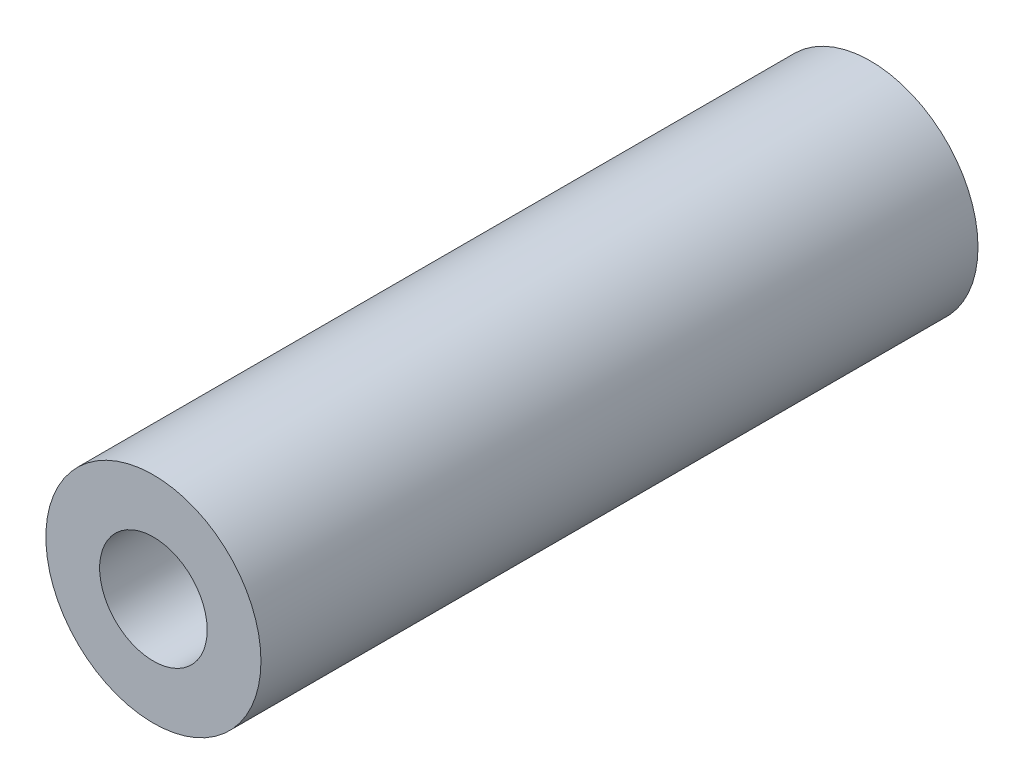
from build123d import *

# Parameters (mm, degrees)
ESQUISSE1_R   = 3
ESQUISSE1_R_2 = 1.5
MAIN_DEPTH    = 20


with BuildPart() as part:
    # Esquisse1 → Main (new body)
    with BuildSketch(Plane.XY):
        Circle(ESQUISSE1_R)
        Circle(ESQUISSE1_R_2, mode=Mode.SUBTRACT)
    extrude(amount=MAIN_DEPTH)


solid = part.part
